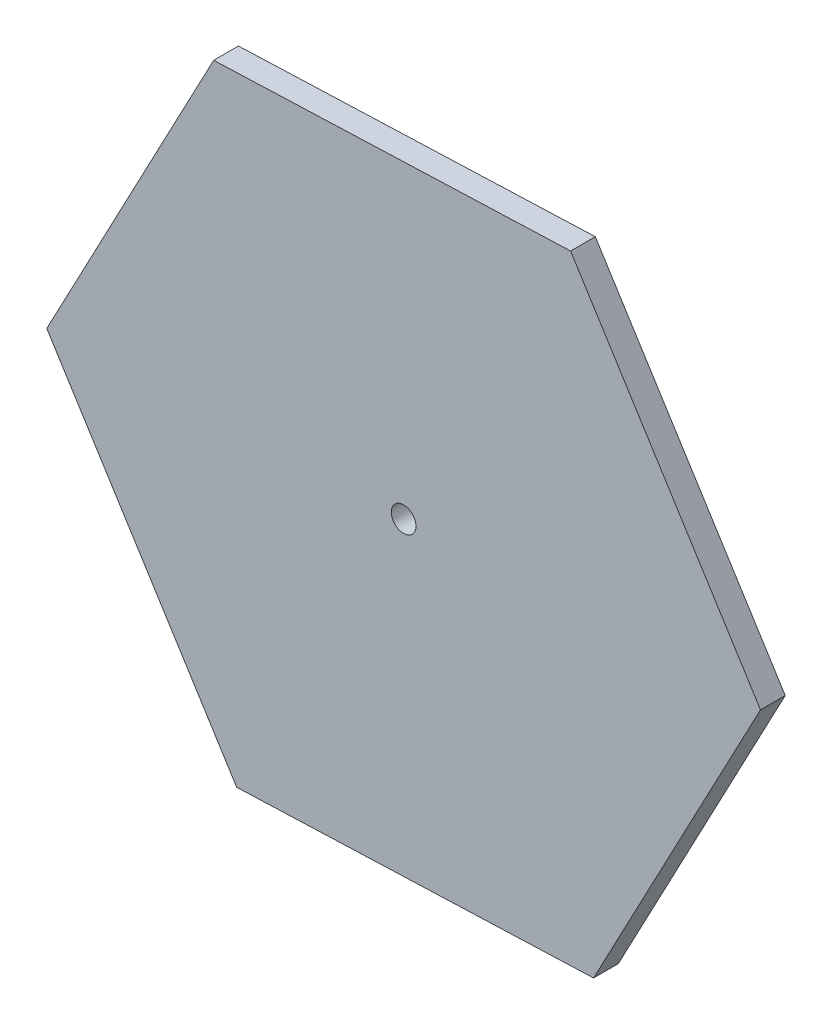
from build123d import *

# Parameters (mm, degrees)
BOSS_EXTRUDE1_DEPTH = 20
SKETCH2_R           = 10
CUT_EXTRUDE1_DEPTH  = 20


with BuildPart() as part:
    # Sketch1 → Boss-Extrude1 (new body)
    with BuildSketch(Plane.XY):
        Polygon((153.531101176, -244.461723599), (288.475613478, 10.73097209), (134.944512302, 255.192695689), (-153.531101176, 244.461723599), (-288.475613478, -10.73097209), (-134.944512302, -255.192695689), align=None)
    extrude(amount=BOSS_EXTRUDE1_DEPTH)

    # Sketch2 → Cut-Extrude1 (cut)
    with BuildSketch(Plane.XY.offset(20)):
        Circle(SKETCH2_R)
    extrude(amount=-CUT_EXTRUDE1_DEPTH, mode=Mode.SUBTRACT)


solid = part.part
